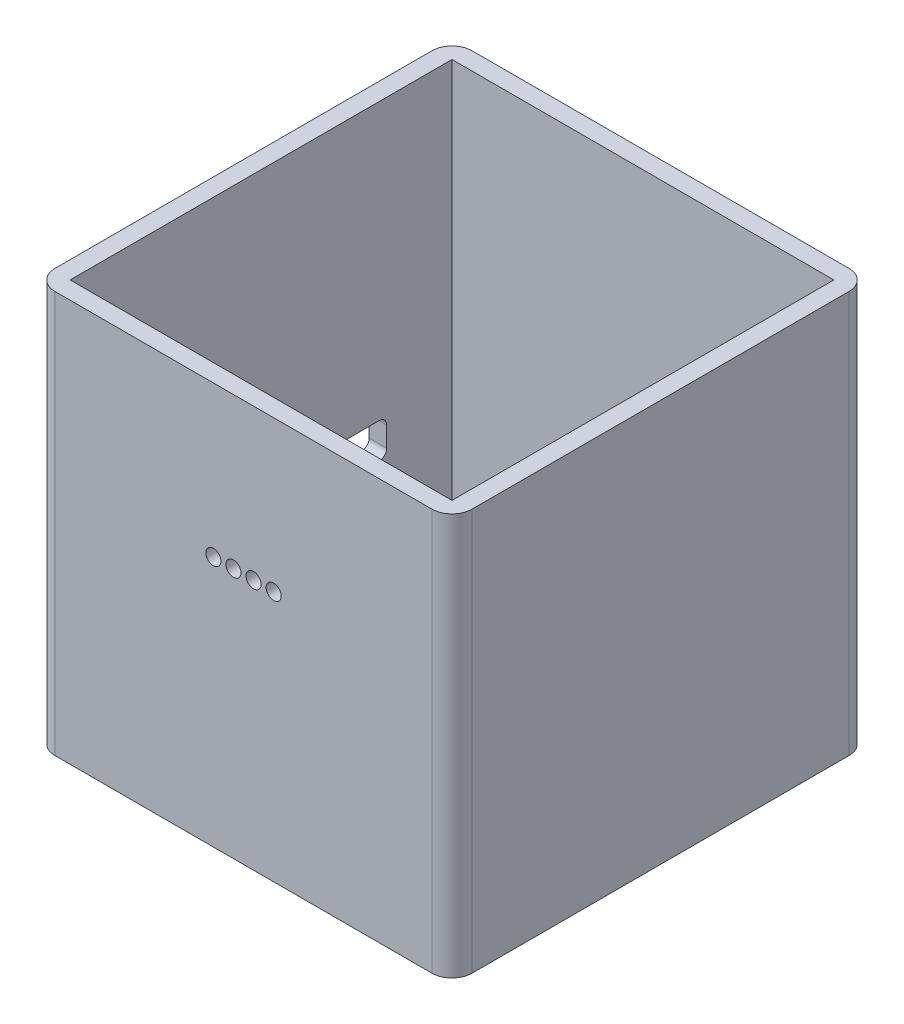
from build123d import *

# Parameters (mm, degrees)
BOSS_EXTRUDE2_DEPTH      = 40
BOSS_EXTRUDE2_DEPTH_BACK = 40
SKETCH4_W                = 83
SKETCH4_H                = 83
CUT_EXTRUDE1_DEPTH       = 50
CUT_EXTRUDE1_DEPTH_BACK  = 37.5
SKETCH5_W                = 76
SKETCH5_H                = 76
CUT_EXTRUDE2_DEPTH       = 74.5
CUT_EXTRUDE2_DEPTH_BACK  = 5
SKETCH6_R                = 1.5
SKETCH8_R                = 1
CUT_EXTRUDE3_DEPTH       = 70.5
SKETCH9_W                = 12
SKETCH9_H                = 7
CUT_EXTRUDE4_DEPTH       = 108.5
FILLET2_R                = 1
FILLET3_R                = 4
SKETCH10_W               = 10
SKETCH10_H               = 7
CUT_EXTRUDE5_DEPTH       = 83
FILLET4_R                = 1.5
SKETCH11_R               = 2
BOSS_EXTRUDE4_DEPTH      = 5
SKETCH12_R               = 1.2
BOSS_EXTRUDE5_DEPTH      = 10


with BuildPart() as part:
    # Sketch4 → Boss-Extrude2 (new, two sides: drawn at the far end of the back side and taken through both)
    with BuildSketch(Plane(origin=(0, 0, 0), x_dir=(1, 0, 0), z_dir=(0, 1, 0)).offset(-BOSS_EXTRUDE2_DEPTH_BACK)):
        Rectangle(SKETCH4_W, SKETCH4_H)
    extrude(amount=BOSS_EXTRUDE2_DEPTH + BOSS_EXTRUDE2_DEPTH_BACK)

    # Sketch5 → Cut-Extrude1 (cut, two sides: drawn at the far end of the back side and taken through both)
    with BuildSketch(Plane(origin=(0, 0, 0), x_dir=(1, 0, 0), z_dir=(0, 1, 0)).offset(-CUT_EXTRUDE1_DEPTH_BACK)):
        Rectangle(SKETCH5_W, SKETCH5_H)
    extrude(amount=CUT_EXTRUDE1_DEPTH + CUT_EXTRUDE1_DEPTH_BACK, mode=Mode.SUBTRACT)

    # Sketch6 → Cut-Extrude2 (cut, two sides: drawn at the far end of the back side and taken through both)
    with BuildSketch(Plane.XY.offset(-CUT_EXTRUDE2_DEPTH_BACK)):
        with Locations((2, 10)):
            Circle(SKETCH6_R)
        with Locations((6, 10)):
            Circle(SKETCH6_R)
        with Locations((-2, 10)):
            Circle(SKETCH6_R)
        with Locations((-6, 10)):
            Circle(SKETCH6_R)
    extrude(amount=CUT_EXTRUDE2_DEPTH + CUT_EXTRUDE2_DEPTH_BACK, mode=Mode.SUBTRACT)

    # Sketch8 → Cut-Extrude3 (cut)
    with BuildSketch(Plane.XY):
        with Locations((0, -9)):
            Circle(SKETCH8_R)
        with Locations((2.5, -9)):
            Circle(SKETCH8_R)
        with Locations((0, -6.5)):
            Circle(SKETCH8_R)
        with Locations((-2.5, -9)):
            Circle(SKETCH8_R)
        with Locations((0, -11.5)):
            Circle(SKETCH8_R)
    extrude(amount=-CUT_EXTRUDE3_DEPTH, mode=Mode.SUBTRACT)

    # Sketch9 → Cut-Extrude4 (cut)
    with BuildSketch(Plane.XY):
        with Locations((24, -18.5)):
            Rectangle(SKETCH9_W, SKETCH9_H)
    extrude(amount=-CUT_EXTRUDE4_DEPTH, mode=Mode.SUBTRACT)

    # Fillet2
    fillet2_edges = [part.edges().sort_by_distance(p)[0] for p in [
        (18, -22, -39.75),
        (30, -22, -39.75),
        (18, -15, -39.75),
        (30, -15, -39.75),
    ]]
    fillet(fillet2_edges, radius=FILLET2_R)

    # Fillet3
    fillet3_edges = [part.edges().sort_by_distance(p)[0] for p in [
        (-41.5, 0, 41.5),
        (41.5, 0, -41.5),
        (41.5, 0, 41.5),
        (-41.5, 0, -41.5),
    ]]
    fillet(fillet3_edges, radius=FILLET3_R)

    # Sketch10 → Cut-Extrude5 (cut)
    with BuildSketch(Plane(origin=(0, 0, 0), x_dir=(0, 0, -1), z_dir=(1, 0, 0))):
        with Locations((20, -18.5)):
            Rectangle(SKETCH10_W, SKETCH10_H)
    extrude(amount=-CUT_EXTRUDE5_DEPTH, mode=Mode.SUBTRACT)

    # Fillet4
    fillet4_edges = [part.edges().sort_by_distance(p)[0] for p in [
        (-39.75, -22, -15),
        (-39.75, -22, -25),
        (-39.75, -15, -15),
        (-39.75, -15, -25),
    ]]
    fillet(fillet4_edges, radius=FILLET4_R)

    # Sketch11 → Boss-Extrude4 (add)
    with BuildSketch(Plane(origin=(0, -37.5, 0), x_dir=(1, 0, 0), z_dir=(0, 1, 0))):
        with Locations((30.875, 27.5)):
            Circle(SKETCH11_R)
        with Locations((-30.875, 27.5)):
            Circle(SKETCH11_R)
        with Locations((-30.875, -27.5)):
            Circle(SKETCH11_R)
        with Locations((30.875, -27.5)):
            Circle(SKETCH11_R)
    extrude(amount=BOSS_EXTRUDE4_DEPTH)

    # Sketch12 → Boss-Extrude5 (add)
    with BuildSketch(Plane(origin=(0, -37.5, 0), x_dir=(1, 0, 0), z_dir=(0, 1, 0))):
        with Locations((-30.875, 27.5)):
            Circle(SKETCH12_R)
        with Locations((30.875, 27.5)):
            Circle(SKETCH12_R)
        with Locations((-30.875, -27.5)):
            Circle(SKETCH12_R)
        with Locations((30.875, -27.5)):
            Circle(SKETCH12_R)
    extrude(amount=BOSS_EXTRUDE5_DEPTH)


solid = part.part
